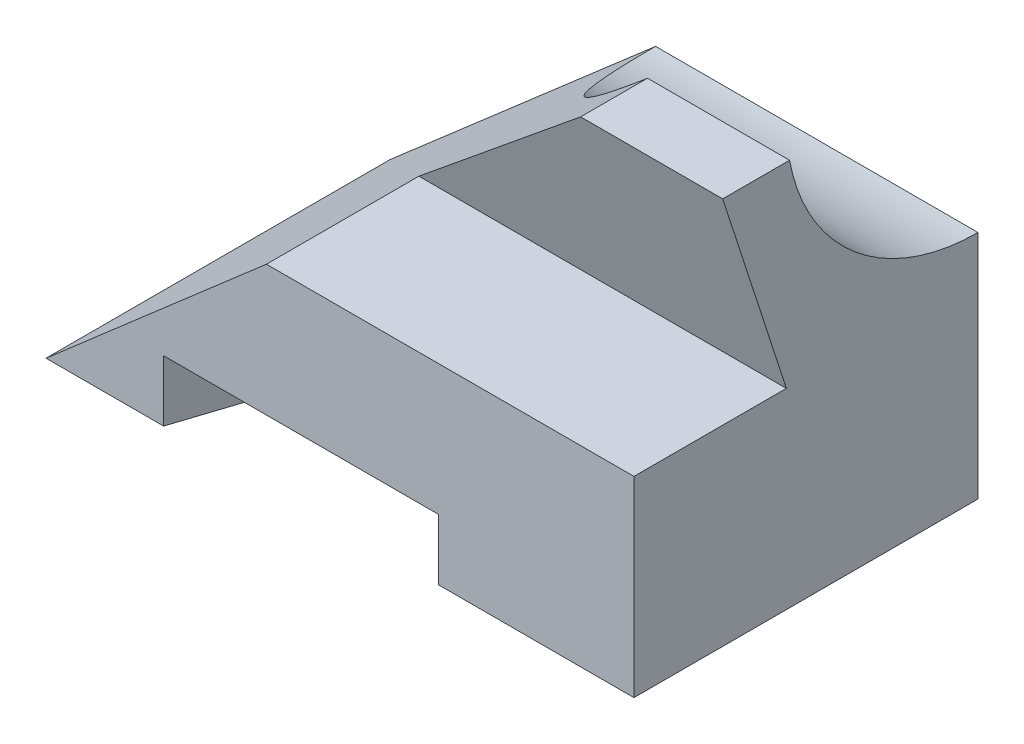
from build123d import *

# Parameters (mm, degrees)
SKETCH2_W                 = 135
SKETCH2_H                 = 79
BASE_MATERIAL_DEPTH       = 89
THRU_ALL_CUTS_DEPTH       = 136
ANGLE_THRU_ALL_DEPTH      = 21.37861367
ANGLE_THRU_ALL_DEPTH_BACK = 59.62138633
CUT_EXTRUDE3_DEPTH        = 14


with BuildPart() as part:
    # Sketch2 → base-material (new body)
    with BuildSketch(Plane(origin=(0, 0, 0), x_dir=(1, 0, 0), z_dir=(0, 1, 0))):
        with Locations((67.5, 39.5)):
            Rectangle(SKETCH2_W, SKETCH2_H)
    extrude(amount=BASE_MATERIAL_DEPTH)

    # Sketch3 → thru-all-cuts (cut, through all)
    with BuildSketch(Plane(origin=(135, 0, 0), x_dir=(0, 0, -1), z_dir=(1, 0, 0))):
        with BuildLine():
            Line((35.733384694, 89), (79, 89))
            Line((79, 89), (79, 53))
            ThreePointArc((79, 53), (50.857505441, 63.176930949), (35.733384694, 89))
        make_face()
        Polygon((0, 44), (35, 44), (20.37861367, 89), (0, 89), align=None)
    extrude(amount=-THRU_ALL_CUTS_DEPTH, mode=Mode.SUBTRACT)

    # Sketch5 → angle-thru-all (cut, two sides)
    with BuildSketch(Plane.XY.offset(-20.37861367)) as angle_thru_all_sk:
        Polygon((0, 0), (102.382788243, 89), (0, 89), align=None)
    extrude(amount=ANGLE_THRU_ALL_DEPTH, mode=Mode.SUBTRACT)
    extrude(angle_thru_all_sk.sketch, amount=-ANGLE_THRU_ALL_DEPTH_BACK, mode=Mode.SUBTRACT)

    # Sketch7 → Cut-Extrude3 (cut)
    with BuildSketch(Plane.XZ):
        Polygon((27, 0), (52.668656002, -79), (115.756389457, -79), (90.087733454, 0), align=None)
    extrude(amount=-CUT_EXTRUDE3_DEPTH, mode=Mode.SUBTRACT)


solid = part.part
